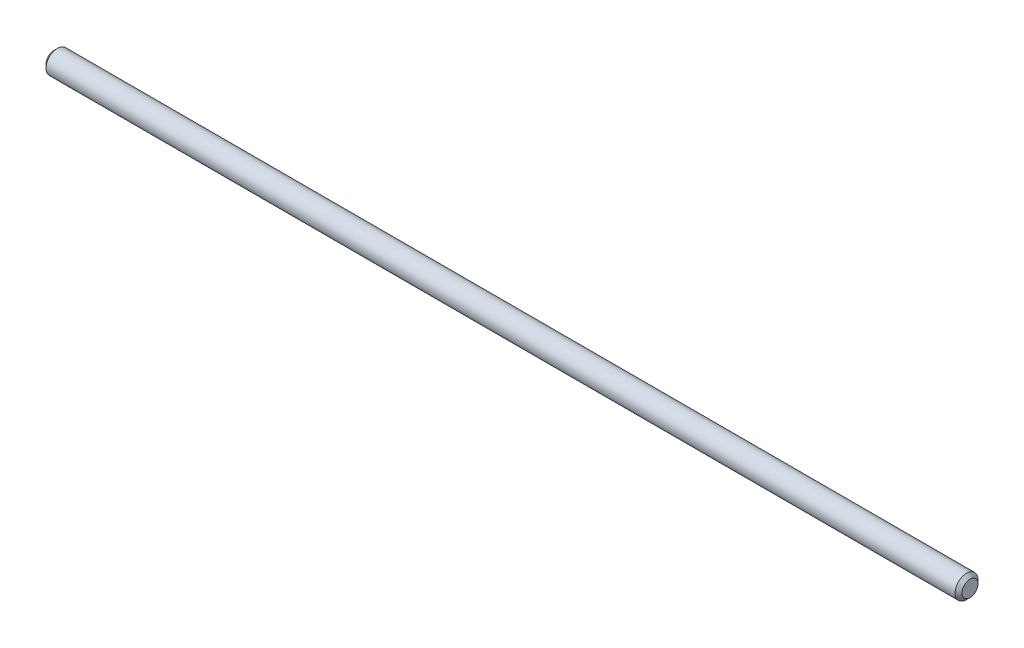
from build123d import *

# Parameters (mm, degrees)
SKETCH1_W     = 800
SKETCH1_H     = 10
CHAMFER1_SIZE = 3


with BuildPart() as part:
    # Sketch1 → Revolve1 (revolve)
    with BuildSketch(Plane.XY):
        with Locations((400, 5)):
            Rectangle(SKETCH1_W, SKETCH1_H)
    revolve(axis=Axis((-457.135147174, 0, 0), (1, 0, 0)))

    # Chamfer1
    chamfer1_edges = [part.edges().sort_by_distance(p)[0] for p in [
        (800, -10, 0),
        (0, -10, 0),
    ]]
    chamfer(chamfer1_edges, length=CHAMFER1_SIZE)


solid = part.part
